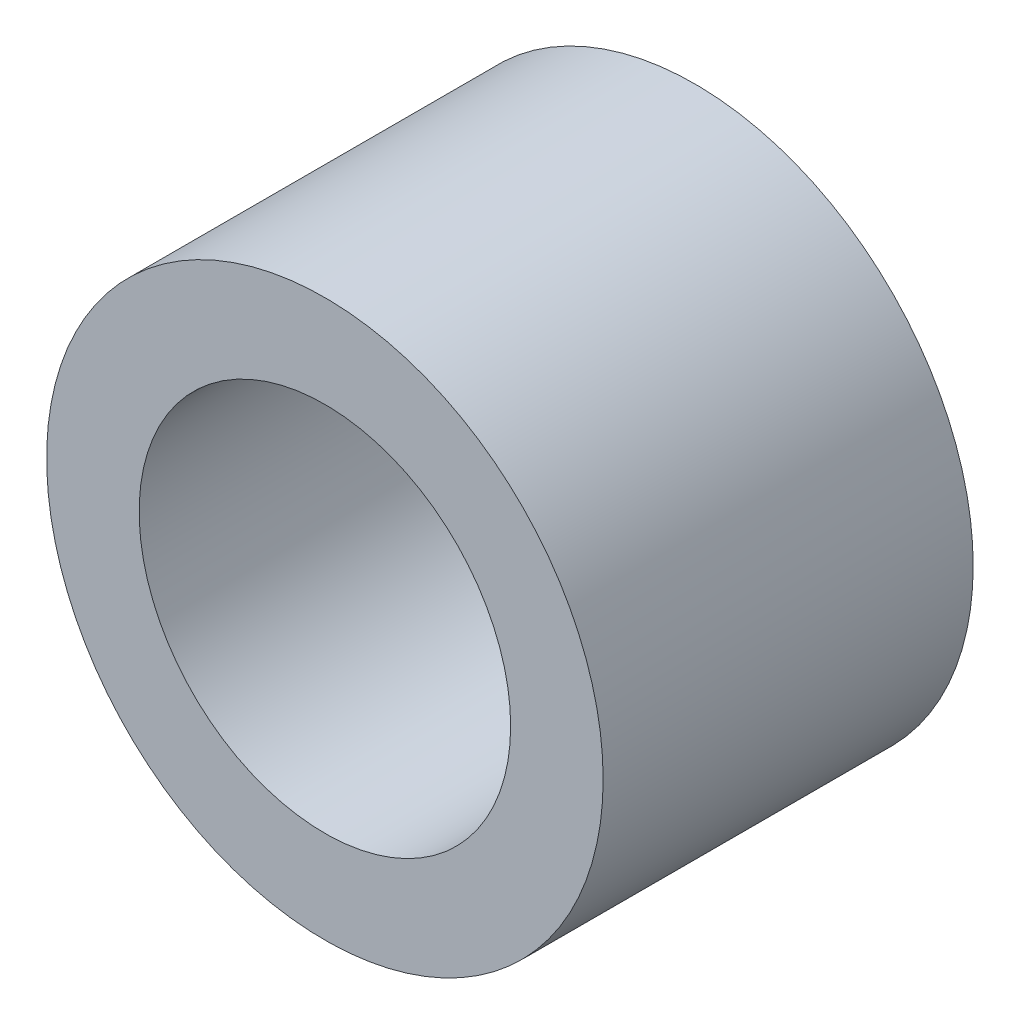
from build123d import *

# Parameters (mm, degrees)
SKETCH1_R      = 4.7752
SKETCH1_R_2    = 3.1877
EXTRUDE1_DEPTH = 3.175


with BuildPart() as part:
    # Sketch1 → Extrude1 (new body, symmetric)
    with BuildSketch(Plane.XY):
        Circle(SKETCH1_R)
        Circle(SKETCH1_R_2, mode=Mode.SUBTRACT)
    extrude(amount=EXTRUDE1_DEPTH, both=True)


solid = part.part
